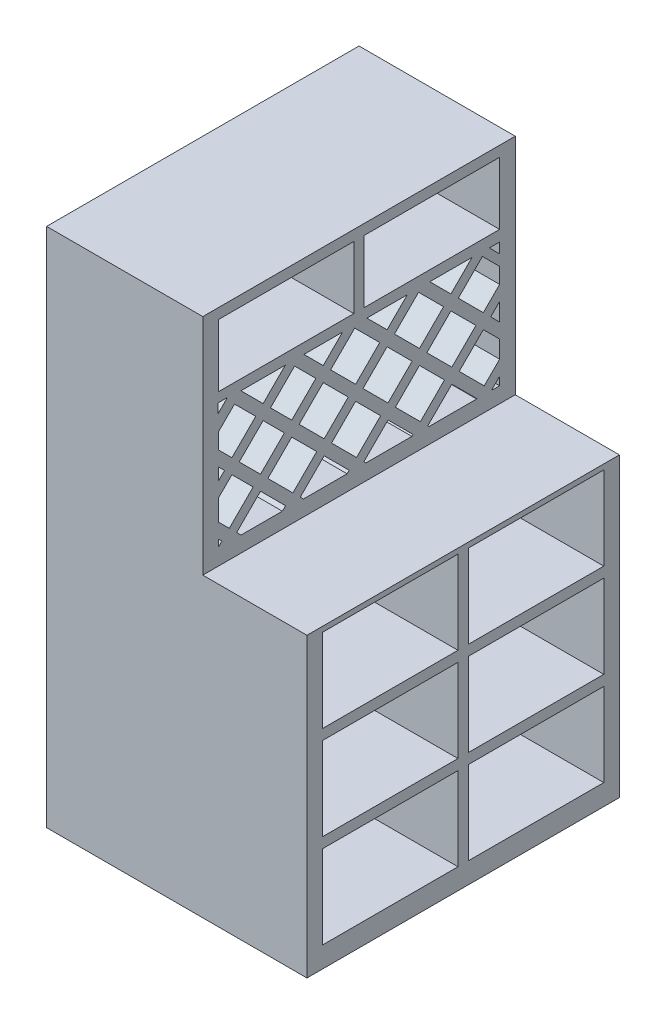
from build123d import *

# Parameters (mm, degrees)
SALIENTE_EXTRUIR1_DEPTH = 30
CROQUIS2_W              = 26
CROQUIS2_H              = 16
CORTAR_EXTRUIR1_DEPTH   = 51
CROQUIS3_W              = 26
CROQUIS3_H              = 12
CORTAR_EXTRUIR2_DEPTH   = 31
CORTAR_EXTRUIR4_DEPTH   = 31
CORTAR_EXTRUIR5_DEPTH   = 31
CORTAR_EXTRUIR6_DEPTH   = 31


with BuildPart() as part:
    # Croquis1 → Saliente-Extruir1 (new body, symmetric)
    with BuildSketch(Plane.XY):
        Polygon((0, 0), (50, 0), (50, 57), (30, 57), (30, 100), (0, 100), align=None)
    extrude(amount=SALIENTE_EXTRUIR1_DEPTH, both=True)

    # Croquis2 → Cortar-Extruir1 (cut, through all)
    with BuildSketch(Plane(origin=(50, 0, 0), x_dir=(0, 0, -1), z_dir=(1, 0, 0))):
        with Locations((-14, 48)):
            Rectangle(CROQUIS2_W, CROQUIS2_H)
        with Locations((14, 48)):
            Rectangle(CROQUIS2_W, CROQUIS2_H)
        with Locations((-14, 30)):
            Rectangle(CROQUIS2_W, CROQUIS2_H)
        with Locations((14, 30)):
            Rectangle(CROQUIS2_W, CROQUIS2_H)
        with Locations((-14, 12)):
            Rectangle(CROQUIS2_W, CROQUIS2_H)
        with Locations((14, 12)):
            Rectangle(CROQUIS2_W, CROQUIS2_H)
    extrude(amount=-CORTAR_EXTRUIR1_DEPTH, mode=Mode.SUBTRACT)

    # Croquis3 → Cortar-Extruir2 (cut, through all)
    with BuildSketch(Plane(origin=(30, 0, 0), x_dir=(0, 0, -1), z_dir=(1, 0, 0))):
        with Locations((-14, 92)):
            Rectangle(CROQUIS3_W, CROQUIS3_H)
        with Locations((14, 92)):
            Rectangle(CROQUIS3_W, CROQUIS3_H)
    extrude(amount=-CORTAR_EXTRUIR2_DEPTH, mode=Mode.SUBTRACT)

    # Croquis4 → Cortar-Extruir4 (cut, through all)
    with BuildSketch(Plane(origin=(30, 0, 0), x_dir=(0, 0, -1), z_dir=(1, 0, 0))):
        Polygon((-23.506160606, 60.828952145), (-22.677208461, 60), (-14.727245643, 60), (-14.116440614, 60.610805028), (-14.166440614, 60.660805028), (-14.216440614, 60.710805028), (-18.920374168, 65.414738582), align=None)
        Polygon((-12.920374168, 71.414738582), (-17.506160606, 66.828952145), (-12.702227052, 62.025018591), (-8.116440614, 66.610805028), align=None)
        Polygon((-6.876072053, 77.459040697), (-11.506160606, 72.828952145), (-6.702227052, 68.025018591), (-2.072138499, 72.655107144), align=None)
        Polygon((-0.831769938, 83.503342813), (-5.46185849, 78.87325426), (-0.657924937, 74.069320706), (3.972163616, 78.699409259), align=None)
        Polygon((1.5, 84), (5.386377179, 80.113622821), (9.272754357, 84), align=None)
        Polygon((-14.159291936, 84), (-22.677208461, 84), (-18.418250198, 79.741041737), align=None)
        Polygon((-10.588604231, 84), (-6.876072053, 80.287467822), (-3.163539875, 84), align=None)
        Polygon((-17.004036636, 78.326828175), (-12.920374168, 74.243165707), (-8.290285615, 78.87325426), (-12.373948083, 82.956916728), align=None)
        Polygon((-23.004036636, 72.326828175), (-18.920374168, 68.243165707), (-14.33458773, 72.828952145), (-18.418250198, 76.912614613), align=None)
        Polygon((-27, 64.322791539), (-24.920374168, 62.243165707), (-20.33458773, 66.828952145), (-24.418250198, 70.912614613), (-27, 68.330864811), align=None)
        Polygon((-27, 61.494364414), (-27, 60.263539875), (-27, 60.163539875), (-26.33458773, 60.828952145), align=None)
        Polygon((27, 67.760177106), (23.866973526, 70.89320358), (19.236884973, 66.263115027), (24.040818527, 61.459181473), (27, 64.418362946), align=None)
        Polygon((13.588604231, 84), (17.64882641, 79.939777821), (21.709048589, 84), align=None)
        Polygon((11.430679294, 83.329497812), (6.800590741, 78.699409259), (11.604524295, 73.895475705), (16.234612848, 78.525564258), align=None)
        Polygon((5.386377179, 77.285195697), (0.756288626, 72.655107144), (5.560222179, 67.85117359), (10.190310732, 72.481262143), align=None)
        Polygon((-0.657924937, 71.240893581), (-5.28801349, 66.610805028), (-0.484079936, 61.806871475), (4.146008617, 66.436960028), align=None)
        Polygon((-1.948293498, 60.442657912), (-1.998293498, 60.492657912), (-6.702227052, 65.196591466), (-11.28801349, 60.610805028), (-10.677208461, 60), (-2.290951411, 60), (-1.898293498, 60.392657912), align=None)
        Polygon((27, 79.848781336), (23.693128525, 83.155652811), (19.063039972, 78.525564258), (23.866973526, 73.721630704), (27, 76.854657178), align=None)
        Polygon((10.364155733, 60.218812911), (10.314155733, 60.268812911), (5.560222179, 65.022746465), (0.930133627, 60.392657912), (1.322791539, 60), (10.145342822, 60), align=None)
        Polygon((17.64882641, 77.111350696), (13.018737857, 72.481262143), (17.822671411, 67.677328589), (22.452759964, 72.307417142), align=None)
        Polygon((11.604524295, 71.067048581), (6.974435742, 66.436960028), (11.778369296, 61.633026474), (16.408457848, 66.263115027), align=None)
        Polygon((-27, 79.326616872), (-27, 76.322791539), (-24.418250198, 73.741041737), (-19.832463761, 78.326828175), (-23.916126229, 82.410490643), align=None)
        Polygon((22.581637054, 60), (22.626604965, 60.044967911), (17.822671411, 64.848901464), (13.192582858, 60.218812911), (13.411395769, 60), align=None)
        Polygon((-27, 71.159291936), (-25.832463761, 72.326828175), (-27, 73.494364414), align=None)
        Polygon((27, 74.026230054), (25.281187089, 72.307417142), (27, 70.588604231), align=None)
        Polygon((27, 61.589935821), (25.455032089, 60.044967911), (25.5, 60), (27, 60), align=None)
    extrude(amount=-CORTAR_EXTRUIR4_DEPTH, mode=Mode.SUBTRACT)

    # Croquis5 → Cortar-Extruir5 (cut, through all)
    with BuildSketch(Plane(origin=(30, 0, 0), x_dir=(0, 0, -1), z_dir=(1, 0, 0))):
        Polygon((-27.085333176, 82.379183427), (-27.085333176, 84.183862587), (-25.280654015, 84.183862587), align=None)
    extrude(amount=-CORTAR_EXTRUIR5_DEPTH, mode=Mode.SUBTRACT)

    # Croquis6 → Cortar-Extruir6 (cut, through all)
    with BuildSketch(Plane(origin=(30, 0, 0), x_dir=(0, 0, -1), z_dir=(1, 0, 0))):
        Polygon((27.009208932, 83.908640009), (27.009208932, 81.911495936), (25.012064859, 83.908640009), align=None)
    extrude(amount=-CORTAR_EXTRUIR6_DEPTH, mode=Mode.SUBTRACT)


solid = part.part
